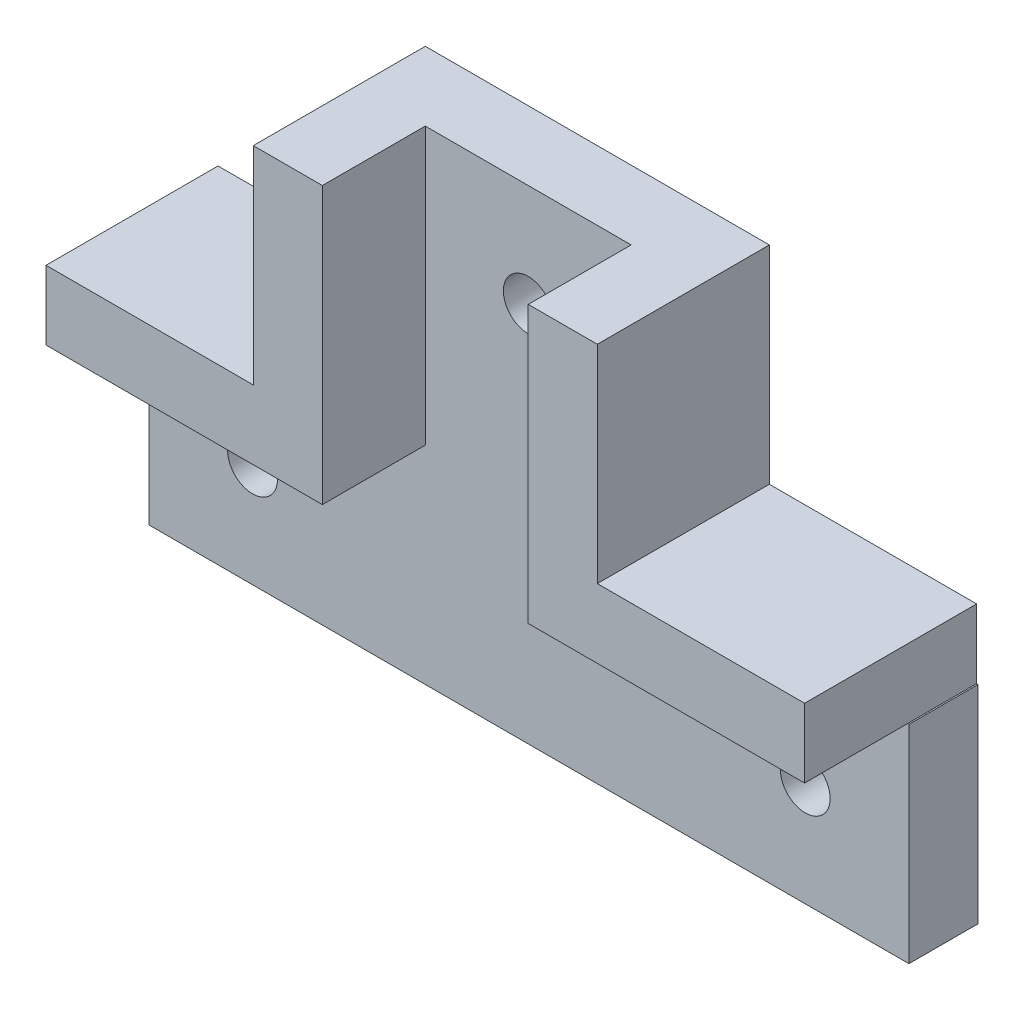
from build123d import *

# Parameters (mm, degrees)
BOSS_EXTRUDE1_DEPTH = 5
BOSS_EXTRUDE2_DEPTH = 12.45
SKETCH6_R           = 1.8
CUT_EXTRUDE3_DEPTH  = 6


with BuildPart() as part:
    # Sketch1 → Boss-Extrude1 (new body)
    with BuildSketch(Plane.XY):
        Polygon((14.31372549, -4.264705882), (34.31372549, -4.264705882), (34.31372549, -19.264705882), (-20.68627451, -19.264705882), (-20.68627451, -4.264705882), (-0.68627451, -4.264705882), (-0.68627451, 15.735294118), (14.31372549, 15.735294118), align=None)
    extrude(amount=BOSS_EXTRUDE1_DEPTH)

    # Sketch2 → Boss-Extrude2 (add)
    with BuildSketch(Plane(origin=(0, 0, 0), x_dir=(-1, 0, 0), z_dir=(0, 0, -1))):
        Polygon((0.68627451, 15.735294118), (5.68627451, 15.735294118), (5.68627451, 0.735294118), (6.079970528, 0.735294118), (20.68627451, 0.735294118), (20.68627451, -4.264705882), (0.68627451, -4.264705882), align=None)
    boss_extrude2 = extrude(amount=-BOSS_EXTRUDE2_DEPTH)

    # Mirror1: Boss-Extrude2 across plane
    add(boss_extrude2.mirror(Plane.ZY.offset(-6.76372549)))

    # Sketch6 → Cut-Extrude3 (cut, through all)
    with BuildSketch(Plane.XY.offset(5)):
        with Locations((6.76372549, 8.235294118)):
            Circle(SKETCH6_R)
        with Locations((-13.18627451, -11.764705882)):
            Circle(SKETCH6_R)
        with Locations((26.81372549, -11.764705882)):
            Circle(SKETCH6_R)
    extrude(amount=-CUT_EXTRUDE3_DEPTH, mode=Mode.SUBTRACT)


solid = part.part
